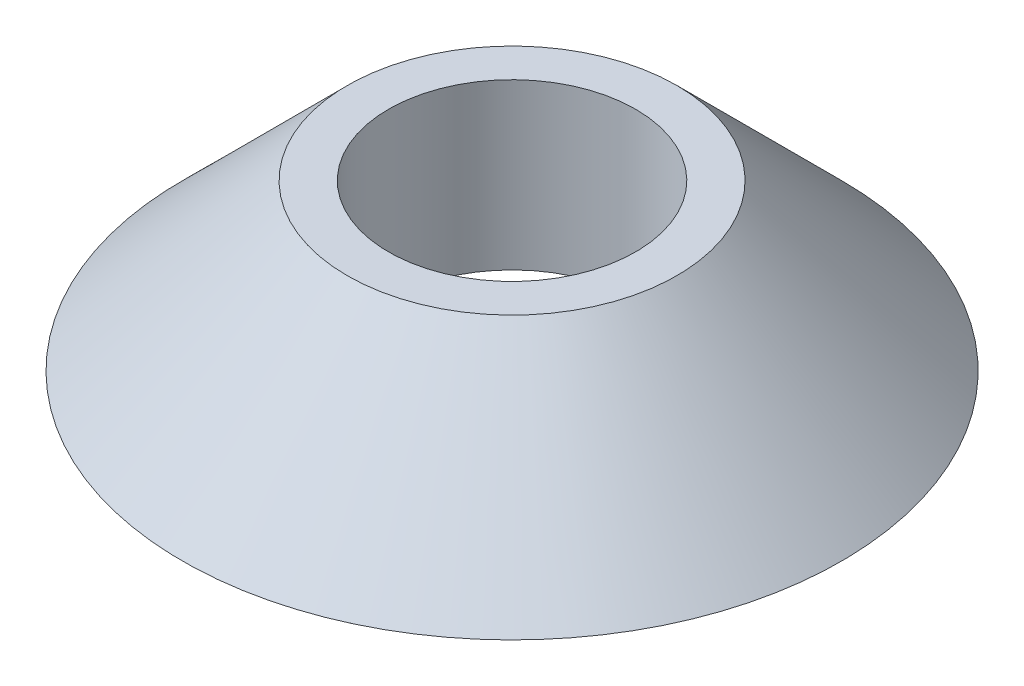
from build123d import *


with BuildPart() as part:
    # Sketch1 → Revolve1 (revolve)
    with BuildSketch(Plane.XY):
        Polygon((9.525, 0), (25.4, 0), (12.7, 12.7), (9.525, 12.7), align=None)
    revolve(axis=Axis((0, -1000.69375591, 0), (0, 1, 0)))


solid = part.part
